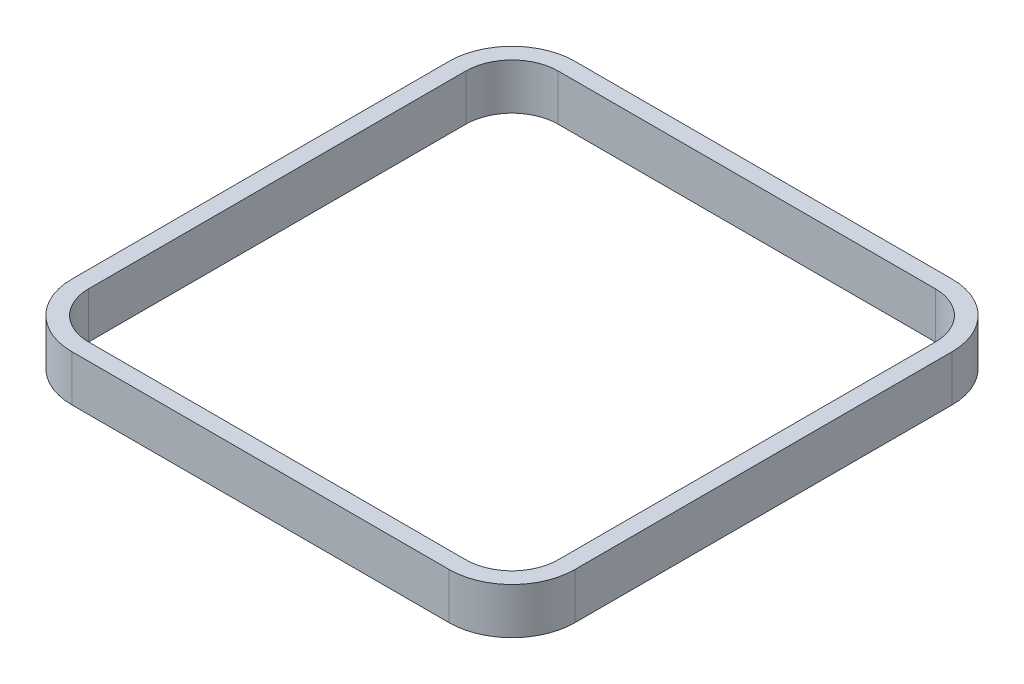
from build123d import *

# Parameters (mm, degrees)
BOSS_EXTRUDE1_DEPTH = 150
CUT_EXTRUDE1_DEPTH  = 110
SKETCH3_R           = 52.074473314
CUT_EXTRUDE2_DEPTH  = 110
CUT_EXTRUDE4_DEPTH  = 40


with BuildPart() as part:
    # Sketch1 → Boss-Extrude1 (new body)
    with BuildSketch(Plane(origin=(0, 0, 0), x_dir=(1, 0, 0), z_dir=(0, 1, 0))):
        with BuildLine():
            Line((-450, -600), (450, -600))
            ThreePointArc((450, -600), (556.066017178, -556.066017178), (600, -450))
            Line((600, -450), (600, 450))
            ThreePointArc((600, 450), (556.066017178, 556.066017178), (450, 600))
            Line((450, 600), (-450, 600))
            ThreePointArc((-450, 600), (-556.066017178, 556.066017178), (-600, 450))
            Line((-600, 450), (-600, -450))
            ThreePointArc((-600, -450), (-556.066017178, -556.066017178), (-450, -600))
        make_face()
    extrude(amount=BOSS_EXTRUDE1_DEPTH)

    # Sketch2 → Cut-Extrude1 (cut)
    with BuildSketch(Plane(origin=(0, 150, 0), x_dir=(1, 0, 0), z_dir=(0, 1, 0))):
        with BuildLine():
            Line((450, 560), (-450, 560))
            ThreePointArc((-450, 560), (-527.781745931, 527.781745931), (-560, 450))
            Line((-560, 450), (-560, -450))
            ThreePointArc((-560, -450), (-527.781745931, -527.781745931), (-450, -560))
            Line((-450, -560), (450, -560))
            ThreePointArc((450, -560), (527.781745931, -527.781745931), (560, -450))
            Line((560, -450), (560, 450))
            ThreePointArc((560, 450), (527.781745931, 527.781745931), (450, 560))
        make_face()
    extrude(amount=-CUT_EXTRUDE1_DEPTH, mode=Mode.SUBTRACT)

    # Sketch3 → Cut-Extrude2 (cut)
    with BuildSketch(Plane(origin=(0, 40, 0), x_dir=(1, 0, 0), z_dir=(0, 1, 0))):
        with Locations((249.348788186, 217.558417351)):
            Circle(SKETCH3_R)
    extrude(amount=-CUT_EXTRUDE2_DEPTH, mode=Mode.SUBTRACT)

    # Sketch7 → Cut-Extrude4 (cut)
    with BuildSketch(Plane.XZ):
        with BuildLine():
            Line((600, -450), (600, 450))
            ThreePointArc((600, 450), (556.066017178, 556.066017178), (450, 600))
            Line((450, 600), (-450, 600))
            ThreePointArc((-450, 600), (-556.066017178, 556.066017178), (-600, 450))
            Line((-600, 450), (-600, -450))
            ThreePointArc((-600, -450), (-556.066017178, -556.066017178), (-450, -600))
            Line((-450, -600), (450, -600))
            ThreePointArc((450, -600), (556.066017178, -556.066017178), (600, -450))
        make_face()
    extrude(amount=-CUT_EXTRUDE4_DEPTH, mode=Mode.SUBTRACT)


solid = part.part
